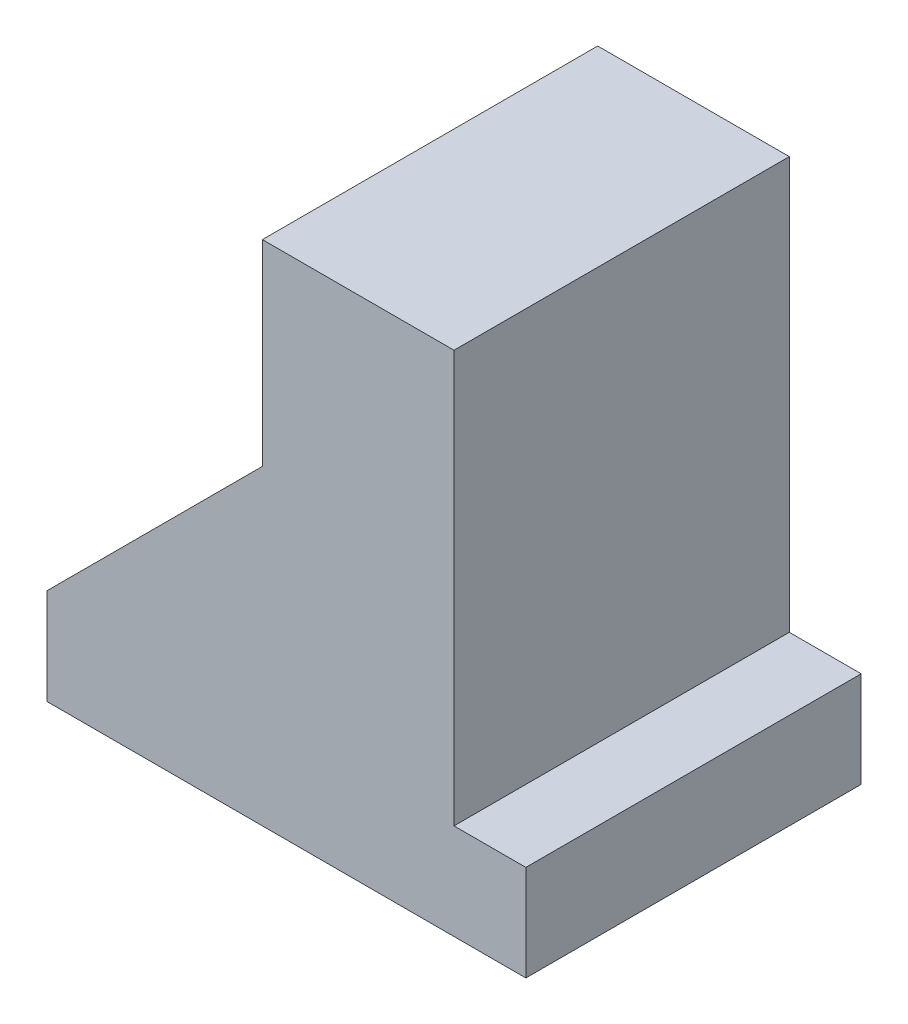
from build123d import *

# Parameters (mm, degrees)
BOSS_EXTRUDE1_DEPTH = 8.89


with BuildPart() as part:
    # Sketch1 → Boss-Extrude1 (new body)
    with BuildSketch(Plane.XY):
        Polygon((0, 0), (12.7, 0), (12.7, 2.54), (10.795, 2.54), (10.795, 13.462), (5.715, 13.462), (5.715, 8.255), (0, 2.54), align=None)
    extrude(amount=BOSS_EXTRUDE1_DEPTH)


solid = part.part
